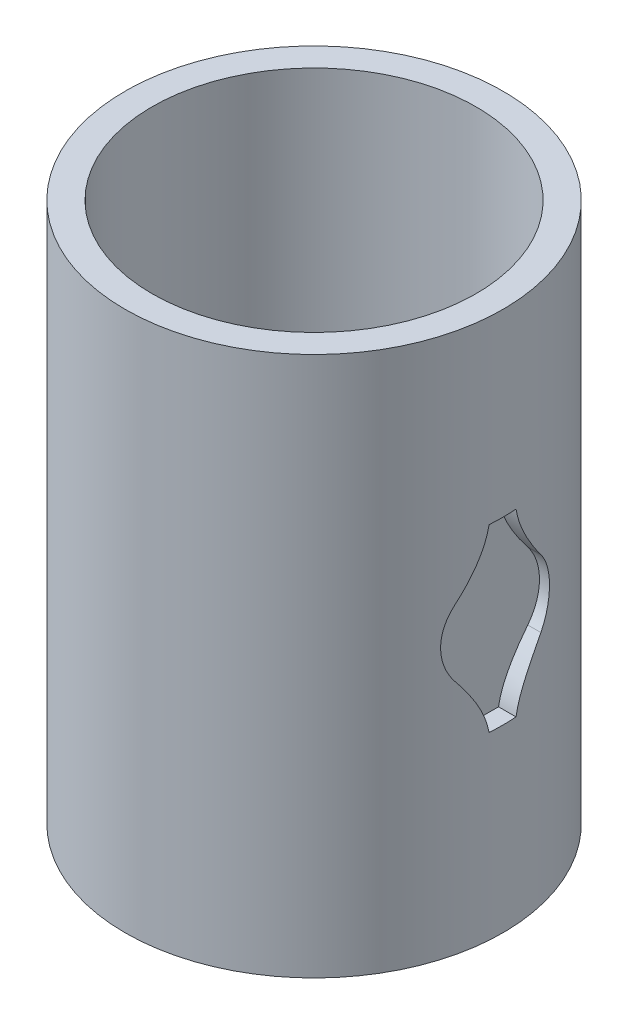
from build123d import *

# Parameters (mm, degrees)
SKETCH1_R           = 10.5
SKETCH1_R_2         = 9
BOSS_EXTRUDE1_DEPTH = 15
CUT_EXTRUDE1_START  = 9.5
CUT_EXTRUDE1_DEPTH  = 2


with BuildPart() as part:
    # Sketch1 → Boss-Extrude1 (new body, symmetric)
    with BuildSketch(Plane(origin=(0, 0, 0), x_dir=(1, 0, 0), z_dir=(0, 1, 0))):
        Circle(SKETCH1_R)
        Circle(SKETCH1_R_2, mode=Mode.SUBTRACT)
    extrude(amount=BOSS_EXTRUDE1_DEPTH, both=True)

    # Sketch2 → Cut-Extrude1 (cut)
    with BuildSketch(Plane(origin=(0, 0, 0), x_dir=(0, 0, -1), z_dir=(1, 0, 0)).offset(CUT_EXTRUDE1_START)):
        with BuildLine():
            ThreePointArc((-2.374052789, 1.874699538), (-1.648827359, 2.536137485), (-0.75, 2.93055029))
            Line((-0.75, 2.93055029), (-0.75, 5))
            add(Edge.make_bspline(
                [(-0.75, 5), (-0.968656254, 3.654443702), (-2.374052789, 1.874699538)],
                knots=[0, 0, 0, 1, 1, 1], degree=2))
        make_face()
        with BuildLine():
            ThreePointArc((-2.374052789, -1.874699538), (-1.648827359, -2.536137485), (-0.75, -2.93055029))
            Line((-0.75, -2.93055029), (-0.75, 2.93055029))
            ThreePointArc((-0.75, 2.93055029), (-1.648827359, 2.536137485), (-2.374052789, 1.874699538))
            ThreePointArc((-2.374052789, 1.874699538), (-3.025, 0), (-2.374052789, -1.874699538))
        make_face()
        with BuildLine():
            Line((0.75, 2.93055029), (0.75, -2.93055029))
            ThreePointArc((0.75, -2.93055029), (1.648827359, -2.536137485), (2.374052789, -1.874699538))
            ThreePointArc((2.374052789, -1.874699538), (2.857633171, -0.992248788), (3.025, 0))
            ThreePointArc((3.025, 0), (2.857633171, 0.992248788), (2.374052789, 1.874699538))
            ThreePointArc((2.374052789, 1.874699538), (1.648827359, 2.536137485), (0.75, 2.93055029))
        make_face()
        with BuildLine():
            Line((0.75, 5), (0.75, 2.93055029))
            ThreePointArc((0.75, 2.93055029), (1.648827359, 2.536137485), (2.374052789, 1.874699538))
            add(Edge.make_bspline(
                [(0.75, 5), (0.968656254, 3.654443702), (2.374052789, 1.874699538)],
                knots=[0, 0, 0, 1, 1, 1], degree=2))
        make_face()
        with BuildLine():
            Line((0.75, -2.93055029), (0.75, -5))
            add(Edge.make_bspline(
                [(0.75, -5), (0.968656254, -3.654443702), (2.374052789, -1.874699538)],
                knots=[0, 0, 0, 1, 1, 1], degree=2))
            ThreePointArc((2.374052789, -1.874699538), (1.648827359, -2.536137485), (0.75, -2.93055029))
        make_face()
        with BuildLine():
            Line((-0.75, -5), (0.75, -5))
            Line((0.75, -5), (0.75, -2.93055029))
            ThreePointArc((0.75, -2.93055029), (0, -3.025), (-0.75, -2.93055029))
            Line((-0.75, -2.93055029), (-0.75, -5))
        make_face()
        with BuildLine():
            add(Edge.make_bspline(
                [(-0.75, -5), (-0.968656254, -3.654443702), (-2.374052789, -1.874699538)],
                knots=[0, 0, 0, 1, 1, 1], degree=2))
            Line((-0.75, -5), (-0.75, -2.93055029))
            ThreePointArc((-0.75, -2.93055029), (-1.648827359, -2.536137485), (-2.374052789, -1.874699538))
        make_face()
        with BuildLine():
            ThreePointArc((-0.75, 2.93055029), (0, 3.025), (0.75, 2.93055029))
            Line((0.75, 2.93055029), (0.75, 5))
            Line((0.75, 5), (-0.75, 5))
            Line((-0.75, 5), (-0.75, 2.93055029))
        make_face()
        with BuildLine():
            ThreePointArc((-0.75, -2.93055029), (0, -3.025), (0.75, -2.93055029))
            Line((0.75, -2.93055029), (0.75, 2.93055029))
            ThreePointArc((0.75, 2.93055029), (0, 3.025), (-0.75, 2.93055029))
            Line((-0.75, 2.93055029), (-0.75, -2.93055029))
        make_face()
    cut_extrude1 = extrude(amount=CUT_EXTRUDE1_DEPTH, mode=Mode.SUBTRACT)

    # Mirror1: Cut-Extrude1 across plane
    add(cut_extrude1.mirror(Plane(origin=(0, 0, 0), x_dir=(0, 0, 1), z_dir=(1, 0, 0))), mode=Mode.SUBTRACT)


solid = part.part
